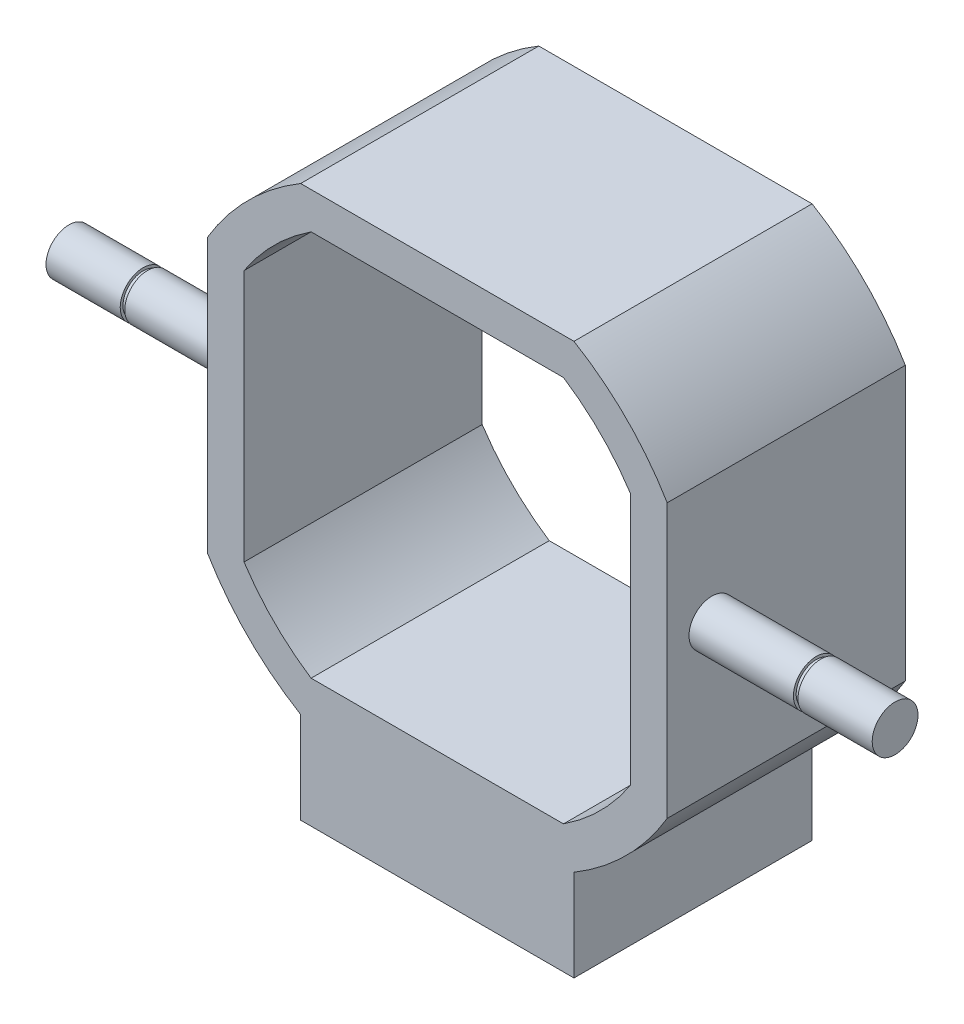
from build123d import *

# Parameters (mm, degrees)
EXTRUDE_THIN1_DEPTH        = 26
SKETCH2_R                  = 2.5
BOSS_EXTRUDE1_DEPTH        = 20
BOSS_EXTRUDE2_START        = -50.2
SKETCH2_3_R                = 2.5
BOSS_EXTRUDE2_DEPTH        = 20
SKETCH3_W                  = 29.841581728
SKETCH3_H                  = 26
BOSS_EXTRUDE3_DEPTH        = 10
WYTNIJ_WYCI_GNI_CIE1_START = -8.6
SZKIC1_R                   = 2.5
SZKIC1_R_2                 = 2.2
WYTNIJ_WYCI_GNI_CIE1_DEPTH = 0.5
WYTNIJ_WYCI_GNI_CIE2_START = -8.6
SZKIC2_R                   = 2.5
SZKIC2_R_2                 = 2.2
WYTNIJ_WYCI_GNI_CIE2_DEPTH = 0.5


with BuildPart() as part:
    # Sketch1 → Extrude-Thin1 (new body)
    with BuildSketch(Plane.XY):
        with BuildLine():
            Line((-25.1, -14.920790864), (-25.1, 14.920790864))
            ThreePointArc((-25.1, 14.920790864), (-20.647518011, 20.647518011), (-14.920790864, 25.1))
            Line((-14.920790864, 25.1), (14.920790864, 25.1))
            ThreePointArc((14.920790864, 25.1), (20.647518011, 20.647518011), (25.1, 14.920790864))
            Line((25.1, 14.920790864), (25.1, -14.920790864))
            ThreePointArc((25.1, -14.920790864), (20.647518011, -20.647518011), (14.920790864, -25.1))
            Line((14.920790864, -25.1), (-14.920790864, -25.1))
            ThreePointArc((-14.920790864, -25.1), (-20.647518011, -20.647518011), (-25.1, -14.920790864))
        make_face()
        with BuildLine():
            Line((-21.1, -13.777880824), (-21.1, 13.777880824))
            ThreePointArc((-21.1, 13.777880824), (-17.819090886, 17.819090886), (-13.777880824, 21.1))
            Line((-13.777880824, 21.1), (13.777880824, 21.1))
            ThreePointArc((13.777880824, 21.1), (17.819090886, 17.819090886), (21.1, 13.777880824))
            Line((21.1, 13.777880824), (21.1, -13.777880824))
            ThreePointArc((21.1, -13.777880824), (17.819090886, -17.819090886), (13.777880824, -21.1))
            Line((13.777880824, -21.1), (-13.777880824, -21.1))
            ThreePointArc((-13.777880824, -21.1), (-17.819090886, -17.819090886), (-21.1, -13.777880824))
        make_face(mode=Mode.SUBTRACT)
    extrude(amount=EXTRUDE_THIN1_DEPTH)

    # Sketch2 → Boss-Extrude1 (add)
    with BuildSketch(Plane.ZY.offset(25.1)):
        with Locations((21.12, 1.16)):
            Circle(SKETCH2_R)
    extrude(amount=BOSS_EXTRUDE1_DEPTH)

    # Sketch2_3 → Boss-Extrude2 (add)
    with BuildSketch(Plane.ZY.offset(25.1).offset(BOSS_EXTRUDE2_START)):
        with Locations((21.12, 1.16)):
            Circle(SKETCH2_3_R)
    extrude(amount=-BOSS_EXTRUDE2_DEPTH)

    # Sketch3 → Boss-Extrude3 (add)
    with BuildSketch(Plane.XZ.offset(25.1)):
        with Locations((0, 13)):
            Rectangle(SKETCH3_W, SKETCH3_H)
    extrude(amount=BOSS_EXTRUDE3_DEPTH)

    # Szkic1 → Wytnij-wyciągnięcie1 (cut)
    with BuildSketch(Plane(origin=(45.1, 0, 0), x_dir=(0, 0, -1), z_dir=(1, 0, 0)).offset(WYTNIJ_WYCI_GNI_CIE1_START)):
        with Locations((-21.12, 1.16)):
            Circle(SZKIC1_R)
        with Locations((-21.12, 1.16)):
            Circle(SZKIC1_R_2, mode=Mode.SUBTRACT)
    extrude(amount=WYTNIJ_WYCI_GNI_CIE1_DEPTH, mode=Mode.SUBTRACT)

    # Szkic2 → Wytnij-wyciągnięcie2 (cut)
    with BuildSketch(Plane.ZY.offset(45.1).offset(WYTNIJ_WYCI_GNI_CIE2_START)):
        with Locations((21.12, 1.16)):
            Circle(SZKIC2_R)
        with Locations((21.12, 1.16)):
            Circle(SZKIC2_R_2, mode=Mode.SUBTRACT)
    extrude(amount=WYTNIJ_WYCI_GNI_CIE2_DEPTH, mode=Mode.SUBTRACT)


solid = part.part
